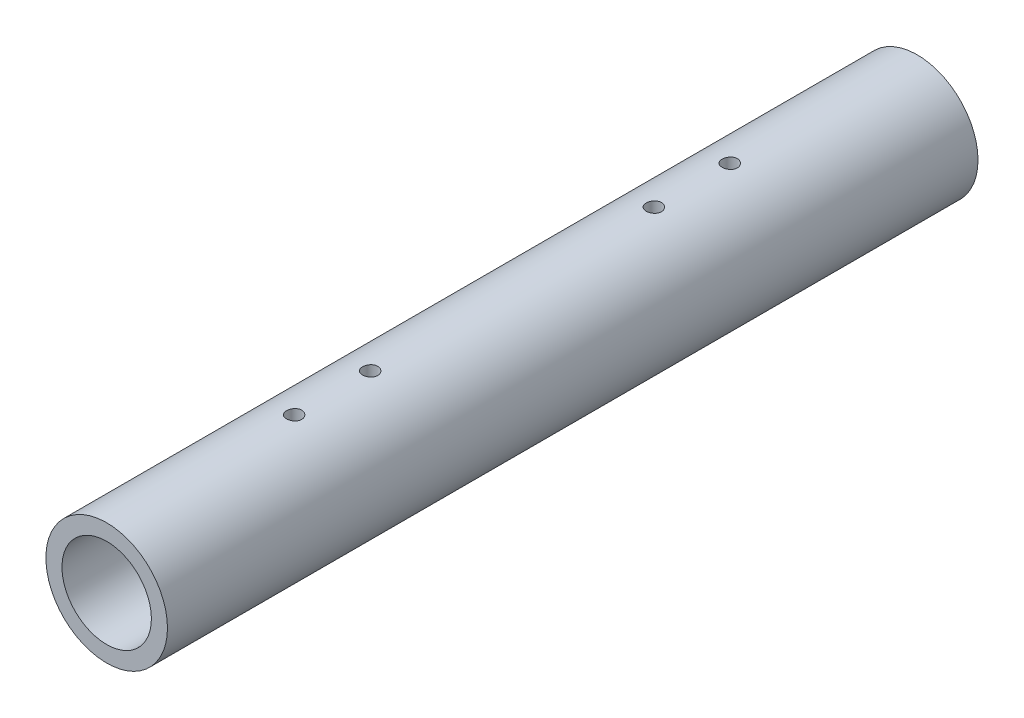
from build123d import *

# Parameters (mm, degrees)
SKETCH1_R               = 12
BOSS_EXTRUDE1_DEPTH     = 80
SHELL1_T                = -3.175
SKETCH3_R               = 1.5
CUT_EXTRUDE1_DEPTH      = 82.780193201
CUT_EXTRUDE1_DEPTH_BACK = 82.780193201


with BuildPart() as part:
    # Sketch1 → Boss-Extrude1 (new, symmetric)
    with BuildSketch(Plane.XY):
        Circle(SKETCH1_R)
    extrude(amount=BOSS_EXTRUDE1_DEPTH, both=True)

    # Shell1
    shell1_openings = [part.faces().sort_by_distance(p)[0] for p in [
        (0, 0, 80),
        (0, 0, -80),
    ]]
    offset(amount=SHELL1_T, openings=shell1_openings, kind=Kind.INTERSECTION)

    # Sketch3 → Cut-Extrude1 (cut, two sides)
    with BuildSketch(Plane(origin=(0, 0, 0), x_dir=(1, 0, 0), z_dir=(0, 1, 0))) as cut_extrude1_sk:
        with Locations(Location((0, 28, 0), (0, 0, 270))):
            Circle(SKETCH3_R)
        with Locations(Location((0, -28, 0), (0, 0, 270))):
            Circle(SKETCH3_R)
        with Locations(Location((0, -43, 0), (0, 0, 270))):
            Circle(SKETCH3_R)
        with Locations(Location((0, 43, 0), (0, 0, 270))):
            Circle(SKETCH3_R)
    extrude(amount=CUT_EXTRUDE1_DEPTH, mode=Mode.SUBTRACT)
    extrude(cut_extrude1_sk.sketch, amount=-CUT_EXTRUDE1_DEPTH_BACK, mode=Mode.SUBTRACT)


solid = part.part
